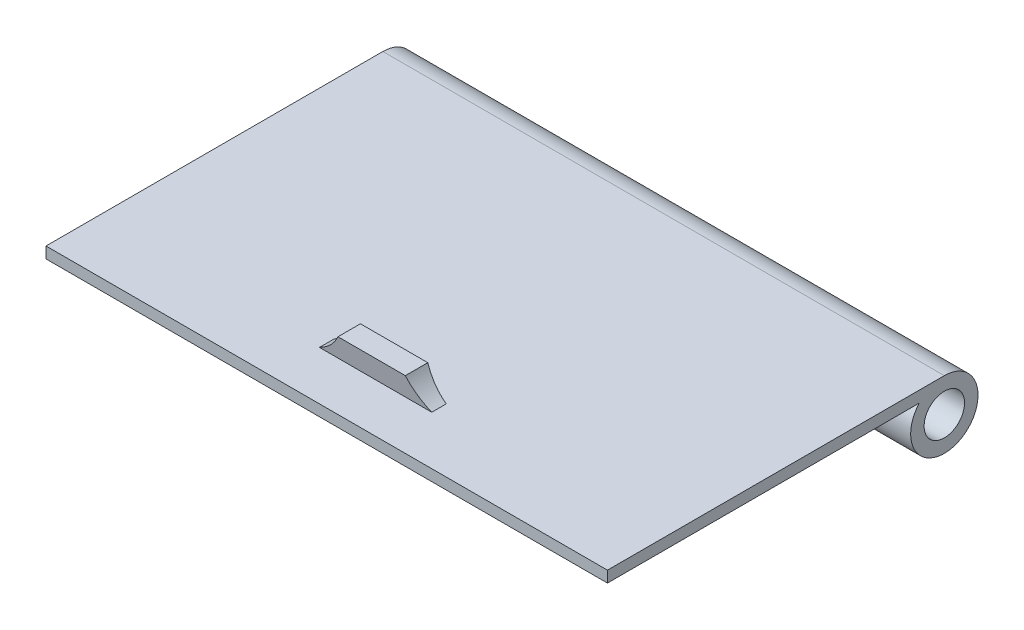
from build123d import *

# Parameters (mm, degrees)
SKETCH1_W           = 48
SKETCH1_H           = 28
BOSS_EXTRUDE1_DEPTH = 1
SKETCH2_W           = 50
SKETCH2_H           = 30
BOSS_EXTRUDE2_DEPTH = 1
SKETCH3_R           = 3
BOSS_EXTRUDE3_DEPTH = 50
SKETCH4_R           = 1.8
CUT_EXTRUDE1_DEPTH  = 51
BOSS_EXTRUDE4_DEPTH = 5
CUT_EXTRUDE2_DEPTH  = 34


with BuildPart() as part:
    # Sketch1 → Boss-Extrude1 (new body)
    with BuildSketch(Plane(origin=(0, 0, 0), x_dir=(1, 0, 0), z_dir=(0, 1, 0))):
        Rectangle(SKETCH1_W, SKETCH1_H)
    extrude(amount=BOSS_EXTRUDE1_DEPTH)

    # Sketch2 → Boss-Extrude2 (add)
    with BuildSketch(Plane(origin=(0, 1, 0), x_dir=(1, 0, 0), z_dir=(0, 1, 0))):
        Rectangle(SKETCH2_W, SKETCH2_H)
    extrude(amount=BOSS_EXTRUDE2_DEPTH)

    # Sketch3 → Boss-Extrude3 (add)
    with BuildSketch(Plane.ZY.offset(25)):
        with Locations((-15, -1)):
            Circle(SKETCH3_R)
    extrude(amount=-BOSS_EXTRUDE3_DEPTH)

    # Sketch4 → Cut-Extrude1 (cut, through all)
    with BuildSketch(Plane.ZY.offset(25)):
        with Locations((-15, -1)):
            Circle(SKETCH4_R)
    extrude(amount=-CUT_EXTRUDE1_DEPTH, mode=Mode.SUBTRACT)

    # Sketch6 → Boss-Extrude4 (add, symmetric)
    with BuildSketch(Plane(origin=(0, 0, 0), x_dir=(0, 0, -1), z_dir=(1, 0, 0))):
        Polygon((-10.647346039, 2), (-11, 4), (-9, 4), (-9.352653961, 2), align=None)
    extrude(amount=BOSS_EXTRUDE4_DEPTH, both=True)

    # Sketch8 → Cut-Extrude2 (cut, through all)
    with BuildSketch(Plane.XY.offset(15)):
        with BuildLine():
            Line((3, 4), (5, 4))
            Line((5, 4), (5, 2))
            ThreePointArc((5, 2), (3.855631086, 2.855631086), (3, 4))
        make_face()
        with BuildLine():
            Line((-5, 4), (-5, 2))
            ThreePointArc((-5, 2), (-3.855631086, 2.855631086), (-3, 4))
            Line((-3, 4), (-5, 4))
        make_face()
    extrude(amount=-CUT_EXTRUDE2_DEPTH, mode=Mode.SUBTRACT)


solid = part.part
